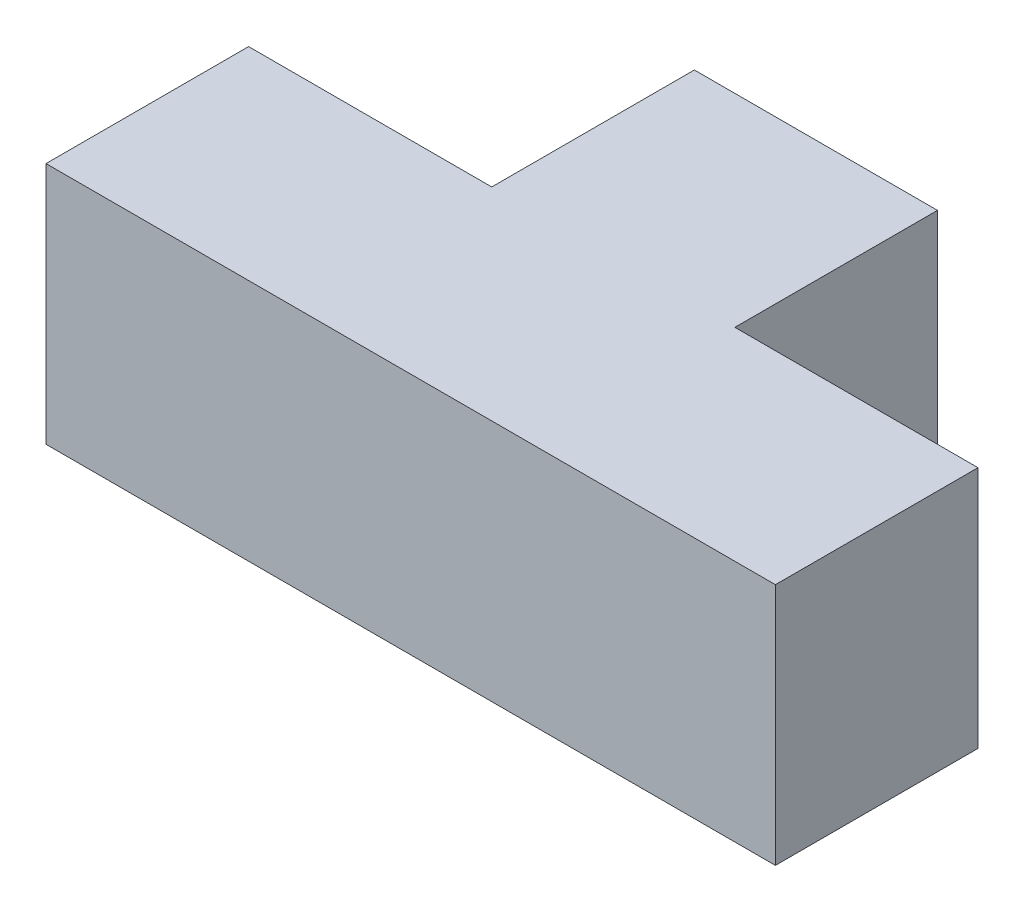
from build123d import *

# Parameters (mm, degrees)
BOSS_EXTRUDE1_DEPTH = 30


with BuildPart() as part:
    # Sketch2 → Boss-Extrude1 (new body)
    with BuildSketch(Plane(origin=(0, 0, 0), x_dir=(1, 0, 0), z_dir=(0, 1, 0))):
        Polygon((-45, 0), (45, 0), (45, 25), (15, 25), (15, 50), (-15, 50), (-15, 25), (-45, 25), align=None)
    extrude(amount=BOSS_EXTRUDE1_DEPTH)


solid = part.part
